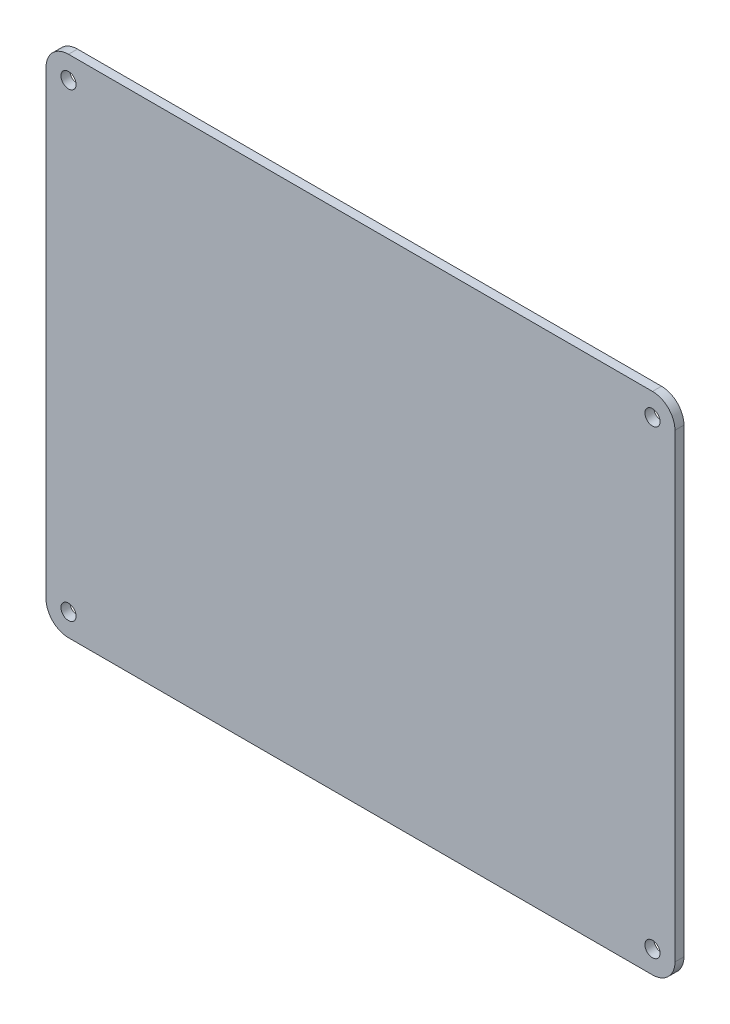
from build123d import *

# Parameters (mm, degrees)
SKETCH1_R           = 1.35
BOSS_EXTRUDE1_DEPTH = 1.6


with BuildPart() as part:
    # Sketch1 → Boss-Extrude1 (new body)
    with BuildSketch(Plane.XY):
        with BuildLine():
            Line((-52, -45), (52, -45))
            ThreePointArc((52, -45), (54.828427125, -43.828427125), (56, -41))
            Line((56, -41), (56, 41))
            ThreePointArc((56, 41), (54.828427125, 43.828427125), (52, 45))
            Line((52, 45), (-52, 45))
            ThreePointArc((-52, 45), (-54.828427125, 43.828427125), (-56, 41))
            Line((-56, 41), (-56, -41))
            ThreePointArc((-56, -41), (-54.828427125, -43.828427125), (-52, -45))
        make_face()
        with Locations((-52, 41)):
            Circle(SKETCH1_R, mode=Mode.SUBTRACT)
        with Locations((52, 41)):
            Circle(SKETCH1_R, mode=Mode.SUBTRACT)
        with Locations((52, -41)):
            Circle(SKETCH1_R, mode=Mode.SUBTRACT)
        with Locations((-52, -41)):
            Circle(SKETCH1_R, mode=Mode.SUBTRACT)
    extrude(amount=BOSS_EXTRUDE1_DEPTH)


solid = part.part
